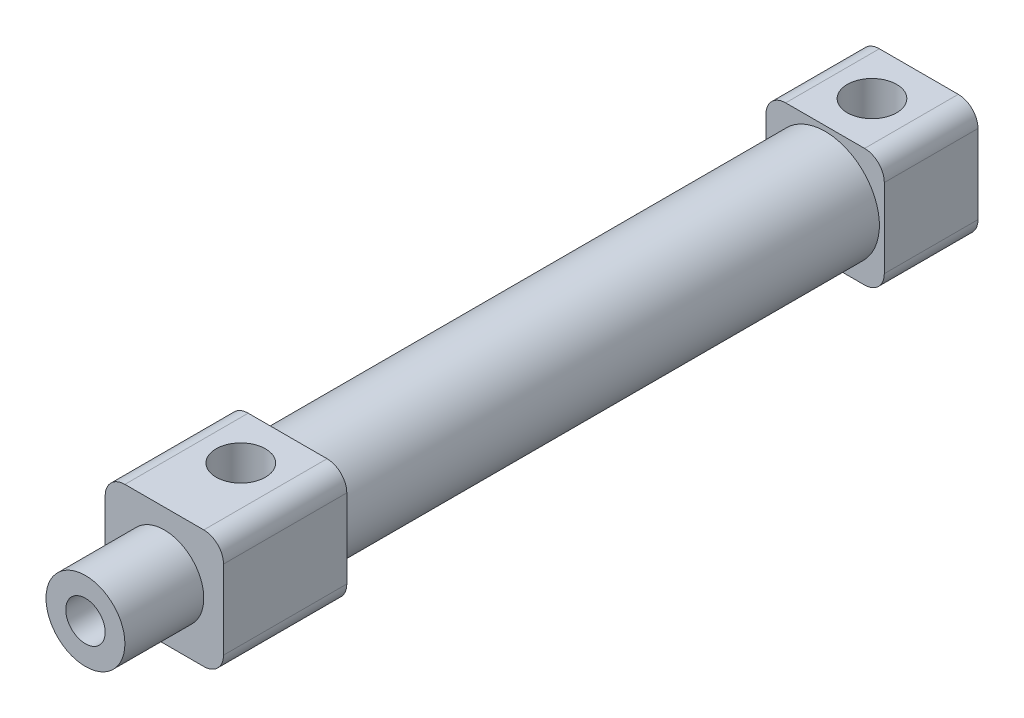
from build123d import *

# Parameters (mm, degrees)
SKETCH_1_W          = 12
SKETCH_1_H          = 12
EXTRUDE_1_DEPTH     = 9.5
SKETCH_2_R          = 5.5
EXTRUDE_2_DEPTH     = 54.5
SKETCH_3_W          = 12
SKETCH_3_H          = 12
EXTRUDE_3_DEPTH     = 12.5
SKETCH_4_R          = 4
EXTRUDE_4_DEPTH     = 8
SKETCH_5_R          = 2
CUT_EXTRUDE_1_DEPTH = 83.5
CUT_EXTRUDE_START   = -6
SKETCH_6_R          = 2.5
CUT_EXTRUDE_2_DEPTH = 6
FILLET_1_R          = 2


with BuildPart() as part:
    # 草图1 → 凸台-拉伸1 (new body)
    with BuildSketch(Plane.XY):
        Rectangle(SKETCH_1_W, SKETCH_1_H)
    extrude(amount=EXTRUDE_1_DEPTH)

    # 草图2 → 凸台-拉伸2 (add)
    with BuildSketch(Plane.XY.offset(9.5)):
        Circle(SKETCH_2_R)
    extrude(amount=EXTRUDE_2_DEPTH)

    # 草图3 → 凸台-拉伸3 (add)
    with BuildSketch(Plane.XY.offset(64)):
        Rectangle(SKETCH_3_W, SKETCH_3_H)
    extrude(amount=EXTRUDE_3_DEPTH)

    # 草图4 → 凸台-拉伸4 (add)
    with BuildSketch(Plane.XY.offset(76.5)):
        Circle(SKETCH_4_R)
    extrude(amount=EXTRUDE_4_DEPTH)

    # 草图5 → 切除-拉伸1 (cut)
    with BuildSketch(Plane.XY.offset(84.5)):
        Circle(SKETCH_5_R)
    extrude(amount=-CUT_EXTRUDE_1_DEPTH, mode=Mode.SUBTRACT)

    # 草图6 → 切除-拉伸2 (cut)
    with BuildSketch(Plane(origin=(0, 6, 0), x_dir=(1, 0, 0), z_dir=(0, 1, 0)).offset(CUT_EXTRUDE_START)):
        with Locations((0, -4.75)):
            Circle(SKETCH_6_R)
        with Locations((0, -68.75)):
            Circle(SKETCH_6_R)
    extrude(amount=CUT_EXTRUDE_2_DEPTH, mode=Mode.SUBTRACT)

    # 圆角1
    fillet_1_edges = [part.edges().sort_by_distance(p)[0] for p in [
        (6, -6, 70.25),
        (6, 6, 70.25),
        (-6, 6, 70.25),
        (-6, -6, 70.25),
        (6, -6, 4.75),
        (-6, -6, 4.75),
        (-6, 6, 4.75),
        (6, 6, 4.75),
    ]]
    fillet(fillet_1_edges, radius=FILLET_1_R)


solid = part.part
